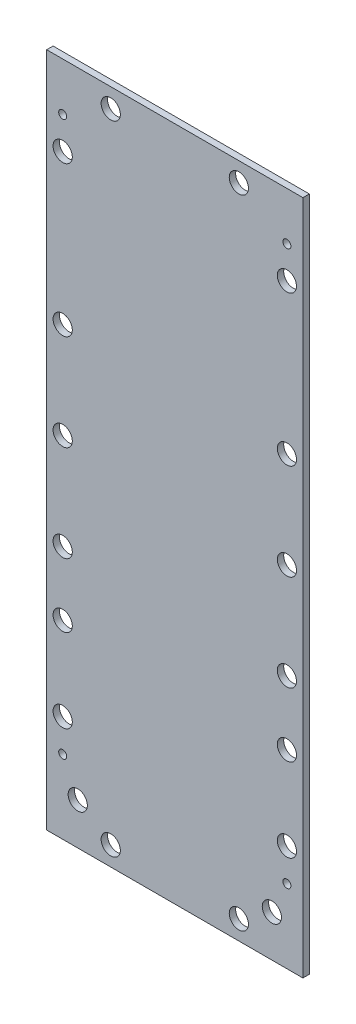
from build123d import *

# Parameters (mm, degrees)
SKETCH2_W                 = 80
SKETCH2_H                 = 211
BOSS_EXTRUDE1_DEPTH       = 2
M3X0_5_TAPPED_HOLE1_D     = 2.5
M3X0_5_TAPPED_HOLE1_DEPTH = 10
M3X0_5_TAPPED_HOLE1_TIP   = 0.751075774
SKETCH7_R                 = 3
CUT_EXTRUDE1_DEPTH        = 2


with BuildPart() as part:
    # Sketch2 → Boss-Extrude1 (new body)
    with BuildSketch(Plane.XY):
        with Locations((40, 105.5)):
            Rectangle(SKETCH2_W, SKETCH2_H)
    extrude(amount=BOSS_EXTRUDE1_DEPTH)

    # M3x0.5 Tapped Hole1
    with Locations(Plane(origin=(0, 0, 0), x_dir=(-1, 0, 0), z_dir=(0, 0, -1))):
        with Locations((-75, 196), (-5, 196), (-75, 23), (-5, 23)):
            Hole(M3X0_5_TAPPED_HOLE1_D / 2, depth=M3X0_5_TAPPED_HOLE1_DEPTH)
            with Locations((0, 0, -(M3X0_5_TAPPED_HOLE1_DEPTH + M3X0_5_TAPPED_HOLE1_TIP / 2))):  # 118° drill point
                Cone(0, M3X0_5_TAPPED_HOLE1_D / 2, M3X0_5_TAPPED_HOLE1_TIP, mode=Mode.SUBTRACT)

    # Sketch7 → Cut-Extrude1 (cut)
    with BuildSketch(Plane(origin=(0, 0, 0), x_dir=(-1, 0, 0), z_dir=(0, 0, -1))):
        with Locations((-75, 186)):
            Circle(SKETCH7_R)
        with Locations((-75, 139.2)):
            Circle(SKETCH7_R)
        with Locations((-75, 109.2)):
            Circle(SKETCH7_R)
        with Locations((-75, 79.2)):
            Circle(SKETCH7_R)
        with Locations((-75, 59.2)):
            Circle(SKETCH7_R)
        with Locations((-75, 33.2)):
            Circle(SKETCH7_R)
        with Locations((-5, 186)):
            Circle(SKETCH7_R)
        with Locations((-5, 139.2)):
            Circle(SKETCH7_R)
        with Locations((-5, 109.2)):
            Circle(SKETCH7_R)
        with Locations((-5, 79.2)):
            Circle(SKETCH7_R)
        with Locations((-5, 59.2)):
            Circle(SKETCH7_R)
        with Locations((-5, 33.2)):
            Circle(SKETCH7_R)
        with Locations((-70.3, 13)):
            Circle(SKETCH7_R)
        with Locations((-60, 205)):
            Circle(SKETCH7_R)
        with Locations((-20, 205)):
            Circle(SKETCH7_R)
        with Locations((-60, 6)):
            Circle(SKETCH7_R)
        with Locations((-20, 6)):
            Circle(SKETCH7_R)
        with Locations((-9.7, 13)):
            Circle(SKETCH7_R)
    extrude(amount=-CUT_EXTRUDE1_DEPTH, mode=Mode.SUBTRACT)


solid = part.part
